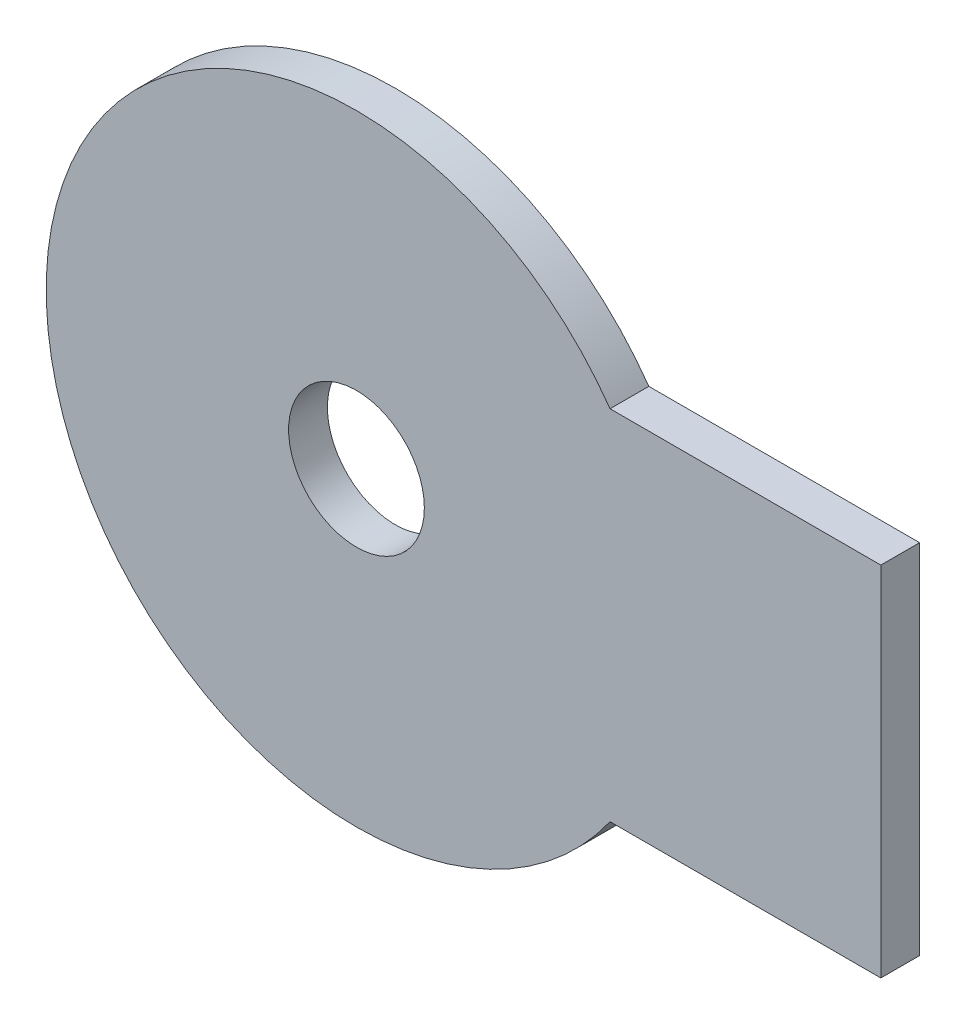
from build123d import *

# Parameters (mm, degrees)
SKETCH1_R           = 101.6
SKETCH1_R_2         = 22.225
SKETCH1_W           = 88.659510459
SKETCH1_H           = 117.09666856
BOSS_EXTRUDE1_DEPTH = 12.7


with BuildPart() as part:
    # Sketch1 → Boss-Extrude1 (new body)
    with BuildSketch(Plane.XY):
        Circle(SKETCH1_R)
        Circle(SKETCH1_R_2, mode=Mode.SUBTRACT)
        with Locations((127.363799772, 0)):
            Rectangle(SKETCH1_W, SKETCH1_H)
    extrude(amount=BOSS_EXTRUDE1_DEPTH)


solid = part.part
